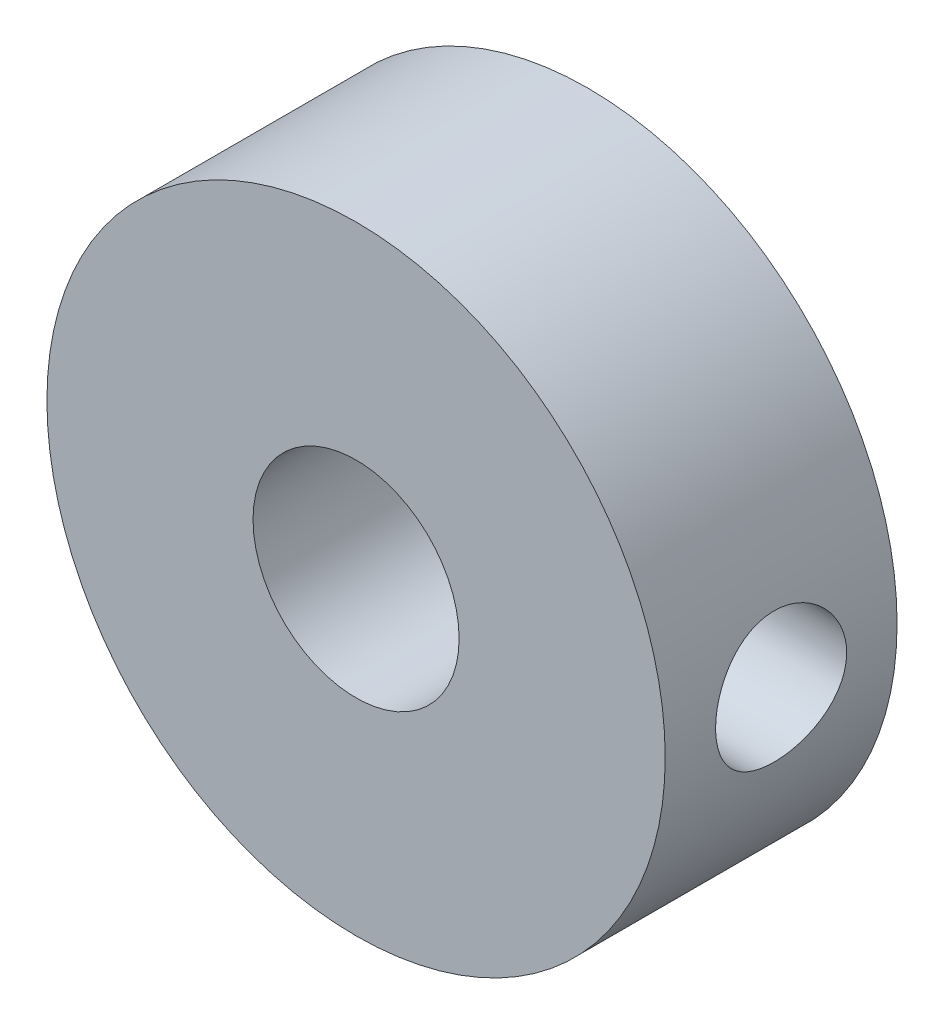
from build123d import *

# Parameters (mm, degrees)
SKETCH1_R                   = 9.525
SKETCH1_R_2                 = 3.175
EXTRUDE1_DEPTH              = 3.571875
F_10_32_TAPPED_HOLE1_REACH  = 23.596
F_10_32_TAPPED_HOLE1_BORE_R = 2.0193


with BuildPart() as part:
    # Sketch1 → Extrude1 (new, symmetric)
    with BuildSketch(Plane.XY):
        Circle(SKETCH1_R)
        Circle(SKETCH1_R_2, mode=Mode.SUBTRACT)
    extrude(amount=EXTRUDE1_DEPTH, both=True)

    # #10-32 Tapped Hole1 bore → #10-32 Tapped Hole1 (cut, up to next)
    with BuildSketch(Plane(origin=(9.525, 0, 0), x_dir=(0, 0, -1), z_dir=(1, 0, 0)), mode=Mode.PRIVATE) as f_10_32_tapped_hole1_sk1:
        Circle(F_10_32_TAPPED_HOLE1_BORE_R)
    f_10_32_tapped_hole1_tool1 = extrude(f_10_32_tapped_hole1_sk1.sketch, amount=-F_10_32_TAPPED_HOLE1_REACH, mode=Mode.PRIVATE) & part.part
    add(f_10_32_tapped_hole1_tool1.solids().sort_by_distance((9.525, 0, 0))[0], mode=Mode.SUBTRACT)


solid = part.part
